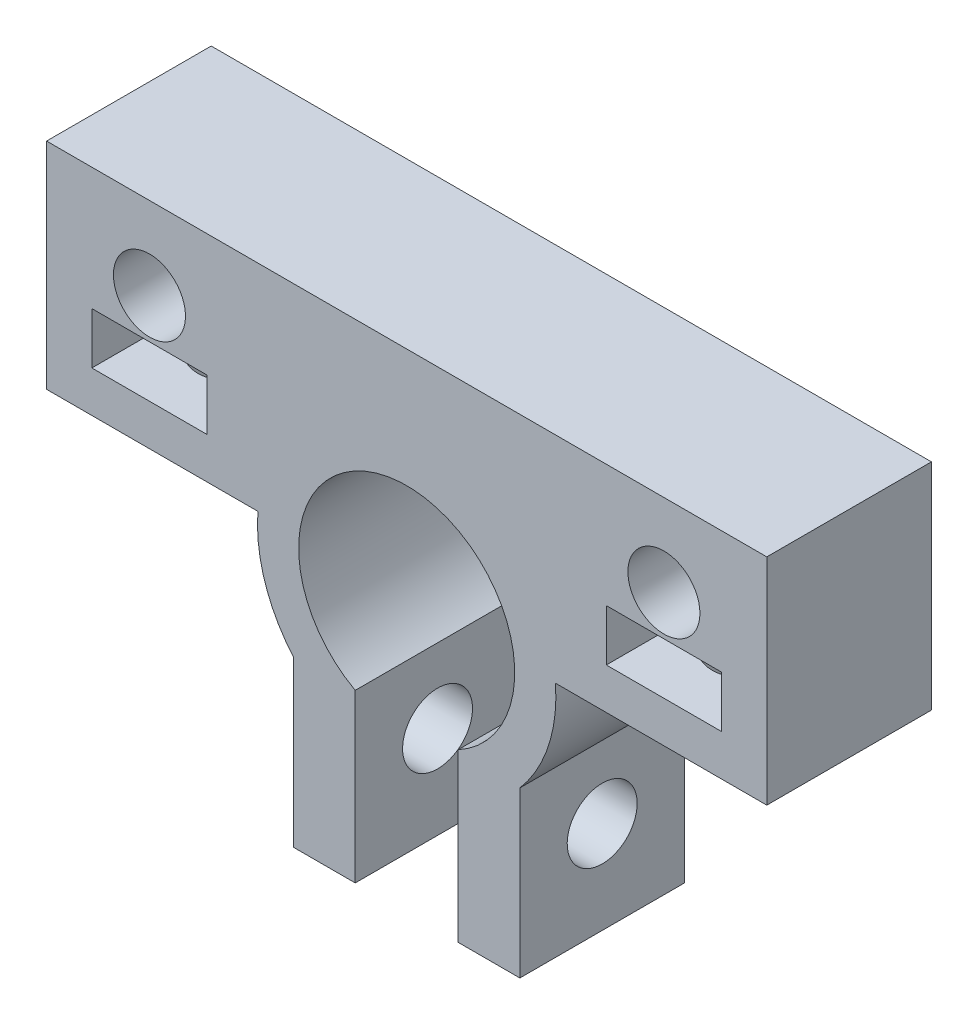
from build123d import *

# Parameters (mm, degrees)
ESBO_O1_R                = 1.75
ESBO_O1_W                = 5.6
ESBO_O1_H                = 2.5
RESSALTO_EXTRUS_O1_DEPTH = 8
ESBO_O2_R                = 1.65
CORTE_EXTRUS_O1_DEPTH    = 7
ESBO_O3_R                = 1.7
CORTE_EXTRUS_O2_DEPTH    = 24


with BuildPart() as part:
    # Esboço1 → Ressalto-extrusão1 (new body)
    with BuildSketch(Plane.XY):
        with BuildLine():
            Line((17.5, 11), (0, 11))
            Line((0, 11), (-17.5, 11))
            Line((-17.5, 11), (-17.5, 0.55))
            Line((-17.5, 0.55), (-7.229107829, 0.55))
            ThreePointArc((-7.229107829, 0.55), (-6.889142873, -2.258807312), (-5.5, -4.723610907))
            Line((-5.5, -4.723610907), (-5.5, -12.723610907))
            Line((-5.5, -12.723610907), (-2.5, -12.723610907))
            Line((-2.5, -12.723610907), (-2.5, -4.616546328))
            ThreePointArc((-2.5, -4.616546328), (0, 5.25), (2.5, -4.616546328))
            Line((2.5, -4.616546328), (2.5, -12.723610907))
            Line((2.5, -12.723610907), (5.5, -12.723610907))
            Line((5.5, -12.723610907), (5.5, -4.723610907))
            ThreePointArc((5.5, -4.723610907), (6.889142873, -2.258807312), (7.229107829, 0.55))
            Line((7.229107829, 0.55), (17.5, 0.55))
            Line((17.5, 0.55), (17.5, 11))
        make_face()
        with Locations((12.5, 7)):
            Circle(ESBO_O1_R, mode=Mode.SUBTRACT)
        with Locations((-12.5, 7)):
            Circle(ESBO_O1_R, mode=Mode.SUBTRACT)
        with Locations((-12.5, 3.8)):
            Rectangle(ESBO_O1_W, ESBO_O1_H, mode=Mode.SUBTRACT)
        with Locations((12.5, 3.8)):
            Rectangle(ESBO_O1_W, ESBO_O1_H, mode=Mode.SUBTRACT)
    extrude(amount=RESSALTO_EXTRUS_O1_DEPTH)

    # Esboço2 → Corte-extrusão1 (cut)
    with BuildSketch(Plane.XZ.offset(-0.55)):
        with Locations((-12.5, 4)):
            Circle(ESBO_O2_R)
        with Locations((12.5, 4)):
            Circle(ESBO_O2_R)
    extrude(amount=-CORTE_EXTRUS_O1_DEPTH, mode=Mode.SUBTRACT)

    # Esboço3 → Corte-extrusão2 (cut, through all)
    with BuildSketch(Plane.ZY.offset(5.5)):
        with Locations((4, -8.223610907)):
            Circle(ESBO_O3_R)
    extrude(amount=-CORTE_EXTRUS_O2_DEPTH, mode=Mode.SUBTRACT)


solid = part.part
